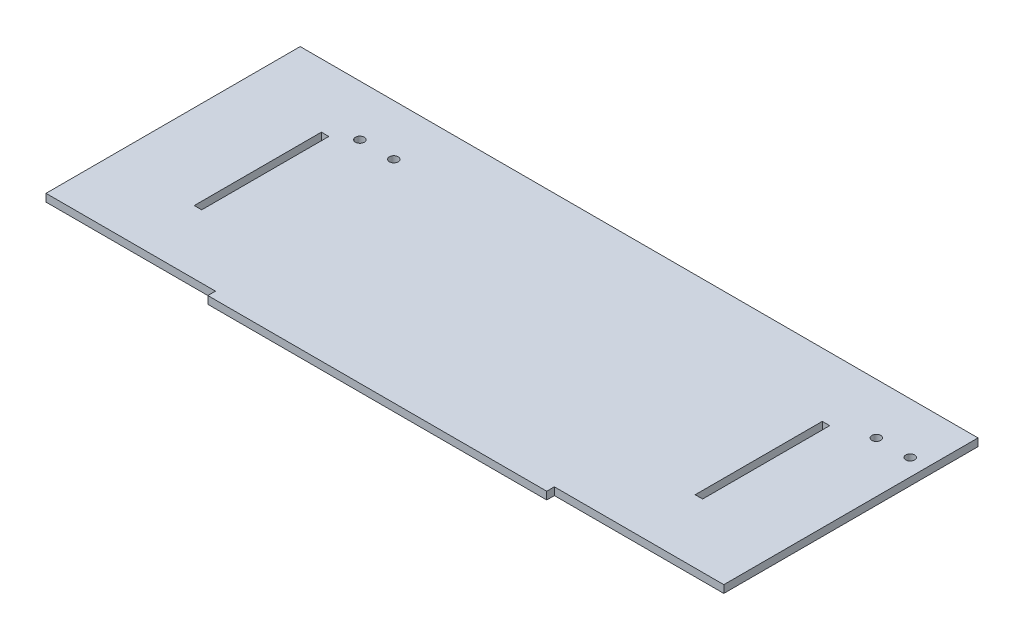
from build123d import *

# Parameters (mm, degrees)
SKETCH1_W           = 200
SKETCH1_H           = 4.5
BOSS_EXTRUDE1_DEPTH = 4.5
SKETCH3_W           = 4.4
SKETCH3_H           = 75
CUT_EXTRUDE1_DEPTH  = 4.5
CUT_EXTRUDE2_REACH  = 6.5
SKETCH5_R           = 2.6


with BuildPart() as part:
    # Sketch1 → Boss-Extrude1 (new body)
    with BuildSketch(Plane(origin=(0, 0, 0), x_dir=(1, 0, 0), z_dir=(0, 1, 0))):
        Polygon((200, 75), (-200, 75), (-200, -75), (-100, -75), (-100, -70.5), (100, -70.5), (100, -75), (200, -75), align=None)
        with Locations((0, -77.25)):
            Rectangle(SKETCH1_W, SKETCH1_H)
        with Locations((0, -72.75)):
            Rectangle(SKETCH1_W, SKETCH1_H)
    extrude(amount=BOSS_EXTRUDE1_DEPTH)

    # Sketch3 → Cut-Extrude1 (cut)
    with BuildSketch(Plane(origin=(0, 4.5, 0), x_dir=(1, 0, 0), z_dir=(0, 1, 0))):
        with Locations((-147.8, 0)):
            Rectangle(SKETCH3_W, SKETCH3_H)
    cut_extrude1 = extrude(amount=-CUT_EXTRUDE1_DEPTH, mode=Mode.SUBTRACT)

    # Mirror1: Cut-Extrude1 across plane
    add(cut_extrude1.mirror(Plane(origin=(0, 0, 0), x_dir=(0, 0, 1), z_dir=(1, 0, 0))), mode=Mode.SUBTRACT)

    # Sketch5 → Cut-Extrude2 (cut, up to next)
    with BuildSketch(Plane(origin=(0, 4.5, 0), x_dir=(1, 0, 0), z_dir=(0, 1, 0)), mode=Mode.PRIVATE) as cut_extrude2_sk1:
        with Locations((-114.777861762, 45)):
            Circle(SKETCH5_R)
    cut_extrude2_tool1 = extrude(cut_extrude2_sk1.sketch, amount=-CUT_EXTRUDE2_REACH, mode=Mode.PRIVATE) & part.part
    add(cut_extrude2_tool1.solids().sort_by_distance((-114.777862, 4.5, -45))[0], mode=Mode.SUBTRACT)
    # Sketch5 → Cut-Extrude2 (cut, up to next)
    with BuildSketch(Plane(origin=(0, 4.5, 0), x_dir=(1, 0, 0), z_dir=(0, 1, 0)), mode=Mode.PRIVATE) as cut_extrude2_sk2:
        with Locations((170, 45)):
            Circle(SKETCH5_R)
    cut_extrude2_tool2 = extrude(cut_extrude2_sk2.sketch, amount=-CUT_EXTRUDE2_REACH, mode=Mode.PRIVATE) & part.part
    add(cut_extrude2_tool2.solids().sort_by_distance((170, 4.5, -45))[0], mode=Mode.SUBTRACT)
    # Sketch5 → Cut-Extrude2 (cut, up to next)
    with BuildSketch(Plane(origin=(0, 4.5, 0), x_dir=(1, 0, 0), z_dir=(0, 1, 0)), mode=Mode.PRIVATE) as cut_extrude2_sk3:
        with Locations((-134.777861762, 45)):
            Circle(SKETCH5_R)
    cut_extrude2_tool3 = extrude(cut_extrude2_sk3.sketch, amount=-CUT_EXTRUDE2_REACH, mode=Mode.PRIVATE) & part.part
    add(cut_extrude2_tool3.solids().sort_by_distance((-134.777862, 4.5, -45))[0], mode=Mode.SUBTRACT)
    # Sketch5 → Cut-Extrude2 (cut, up to next)
    with BuildSketch(Plane(origin=(0, 4.5, 0), x_dir=(1, 0, 0), z_dir=(0, 1, 0)), mode=Mode.PRIVATE) as cut_extrude2_sk4:
        with Locations((190, 45)):
            Circle(SKETCH5_R)
    cut_extrude2_tool4 = extrude(cut_extrude2_sk4.sketch, amount=-CUT_EXTRUDE2_REACH, mode=Mode.PRIVATE) & part.part
    add(cut_extrude2_tool4.solids().sort_by_distance((190, 4.5, -45))[0], mode=Mode.SUBTRACT)


solid = part.part
